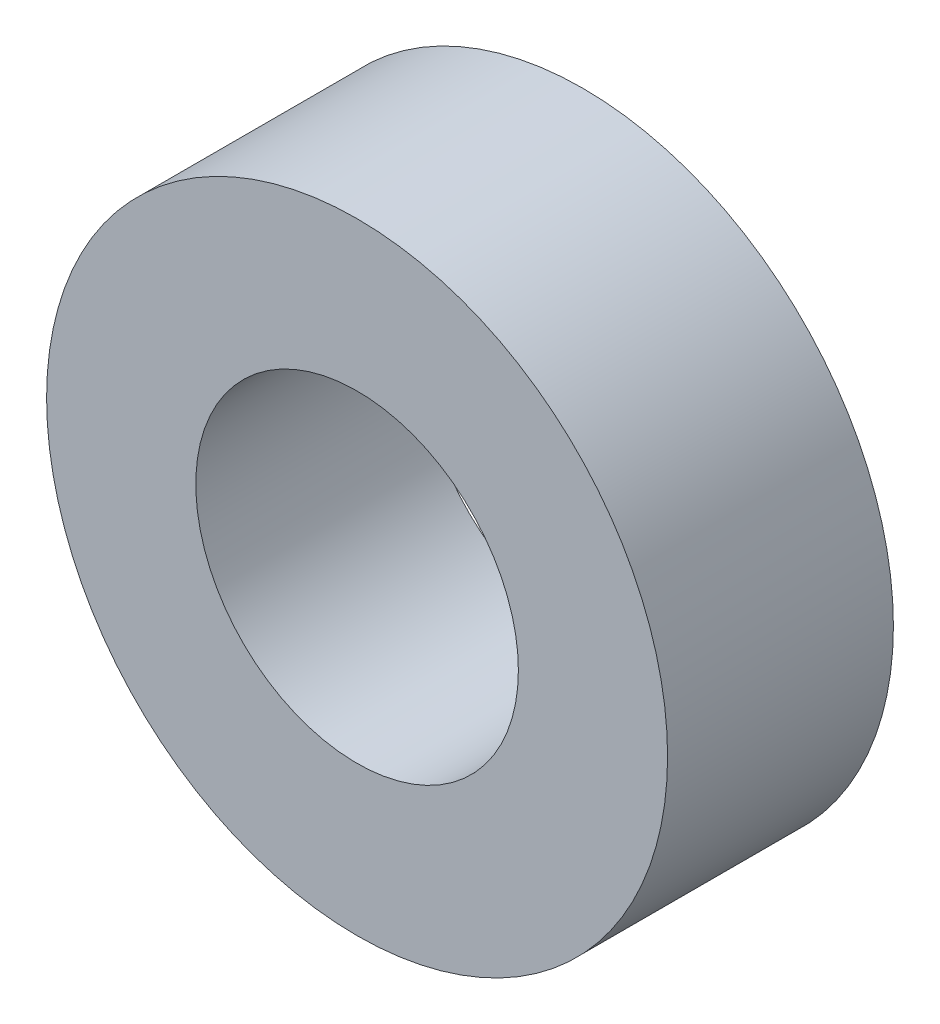
from build123d import *

# Parameters (mm, degrees)
SKETCH_1_R      = 3.85
SKETCH_1_R_2    = 2
EXTRUDE_1_DEPTH = 2.8


with BuildPart() as part:
    # 草圖1 → 填料-伸長1 (new body)
    with BuildSketch(Plane.XY):
        Circle(SKETCH_1_R)
        Circle(SKETCH_1_R_2, mode=Mode.SUBTRACT)
    extrude(amount=EXTRUDE_1_DEPTH)


solid = part.part
